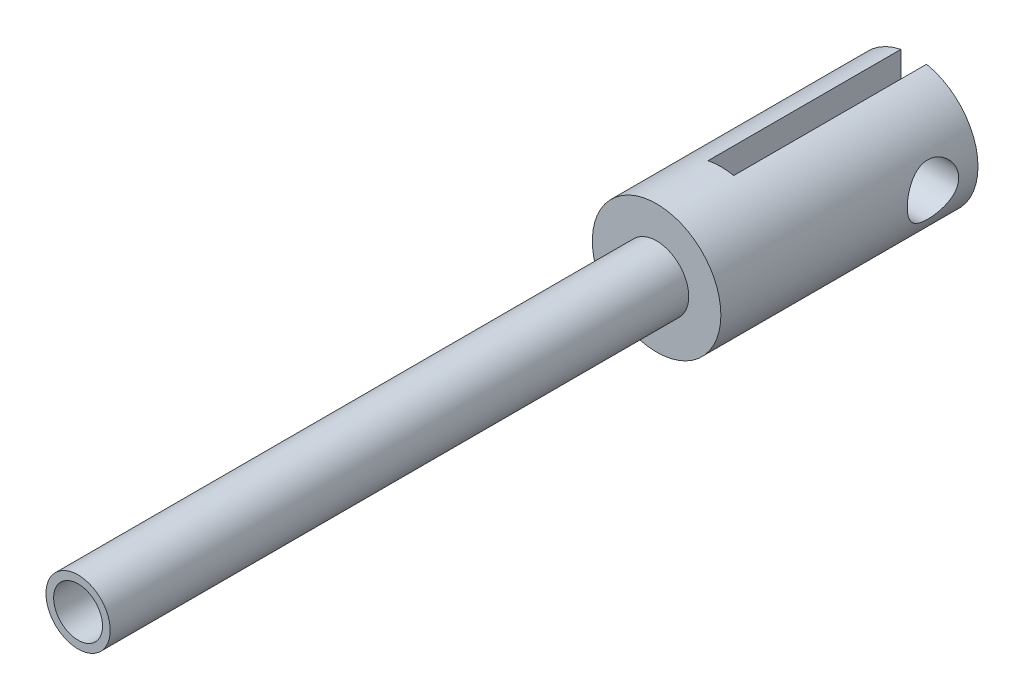
from build123d import *

# Parameters (mm, degrees)
SKETCH2_R               = 10
BOSS_EXTRUDE1_DEPTH     = 40
CUT_EXTRUDE1_DEPTH      = 20
CUT_EXTRUDE1_DEPTH_BACK = 20
SKETCH3_W               = 4
SKETCH3_H               = 30
CUT_EXTRUDE2_DEPTH      = 20
CUT_EXTRUDE2_DEPTH_BACK = 20
SKETCH4_R               = 4
SKETCH5_R               = 5
BOSS_EXTRUDE2_DEPTH     = 90
SKETCH6_R               = 3.8
CUT_EXTRUDE3_DEPTH      = 20


with BuildPart() as part:
    # Sketch2 → Boss-Extrude1 (new body)
    with BuildSketch(Plane.XY):
        Circle(SKETCH2_R)
    extrude(amount=BOSS_EXTRUDE1_DEPTH)

    # Sketch3 → Cut-Extrude1 (cut, two sides: drawn at the far end of the back side and taken through both)
    with BuildSketch(Plane(origin=(0, 0, 0), x_dir=(1, 0, 0), z_dir=(0, 1, 0)).offset(-CUT_EXTRUDE1_DEPTH_BACK)):
        with Locations((0, -15)):
            Rectangle(SKETCH3_W, SKETCH3_H)
    extrude(amount=CUT_EXTRUDE1_DEPTH + CUT_EXTRUDE1_DEPTH_BACK, mode=Mode.SUBTRACT)

    # Sketch4 → Cut-Extrude2 (cut, two sides: drawn at the far end of the back side and taken through both)
    with BuildSketch(Plane(origin=(0, 0, 0), x_dir=(0, 0, -1), z_dir=(1, 0, 0)).offset(-CUT_EXTRUDE2_DEPTH_BACK)):
        with Locations((-7, 0)):
            Circle(SKETCH4_R)
    extrude(amount=CUT_EXTRUDE2_DEPTH + CUT_EXTRUDE2_DEPTH_BACK, mode=Mode.SUBTRACT)

    # Sketch5 → Boss-Extrude2 (add)
    with BuildSketch(Plane.XY.offset(40)):
        Circle(SKETCH5_R)
    extrude(amount=BOSS_EXTRUDE2_DEPTH)

    # Sketch6 → Cut-Extrude3 (cut)
    with BuildSketch(Plane.XY.offset(130)):
        Circle(SKETCH6_R)
    extrude(amount=-CUT_EXTRUDE3_DEPTH, mode=Mode.SUBTRACT)


solid = part.part
